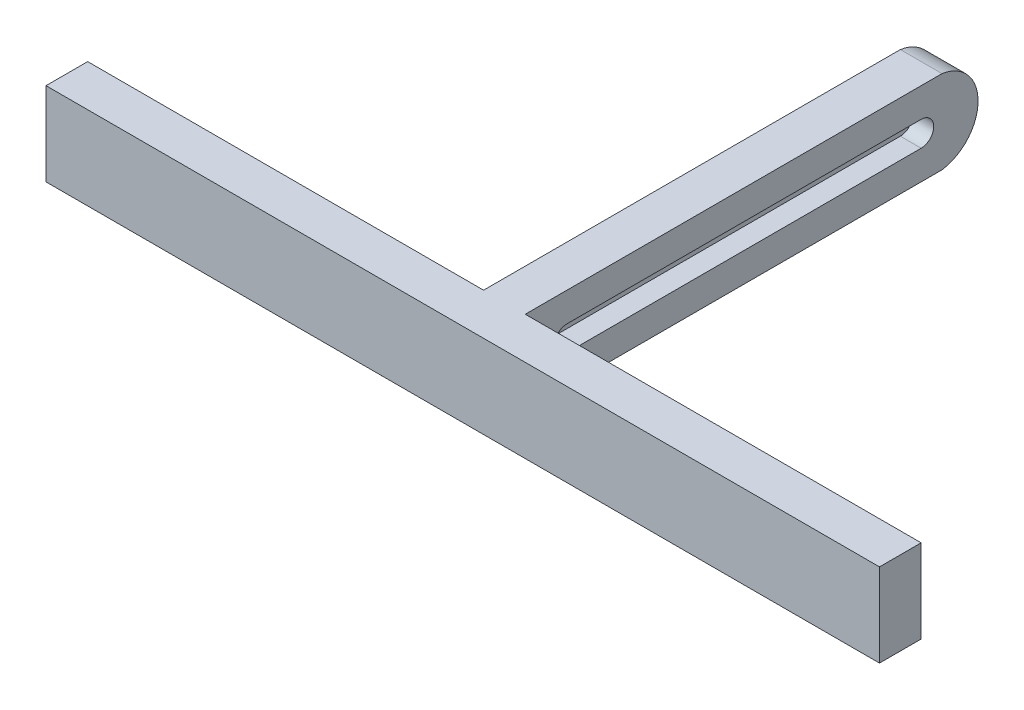
from build123d import *

# Parameters (mm, degrees)
BACK_START      = -5
SKETCH1_W       = 100
SKETCH1_H       = 20
BACK_DEPTH      = 10
CURVE_START     = -5
CURVE_END_DEPTH = 10
SLOT_START      = 5
SLOT_DEPTH      = 5
FRONT_START     = -100
SKETCH11_W      = 10
SKETCH11_H      = 20
FRONT_DEPTH     = 200


with BuildPart() as part:
    # Sketch1 → Back (new body)
    with BuildSketch(Plane(origin=(0, 0, 0), x_dir=(0, 0, -1), z_dir=(1, 0, 0)).offset(BACK_START)):
        Rectangle(SKETCH1_W, SKETCH1_H)
    extrude(amount=BACK_DEPTH)

    # Sketch5 → Curve End (add)
    with BuildSketch(Plane(origin=(0, 0, 0), x_dir=(0, 0, -1), z_dir=(1, 0, 0)).offset(CURVE_START)):
        with BuildLine():
            ThreePointArc((50, 10), (58.658985764, 0), (50, -10))
            Line((50, -10), (48.569993907, -0.102773996))
            ThreePointArc((48.569993907, -0.102773996), (48.658985764, 0), (48.569993907, 0.102773996))
            Line((48.569993907, 0.102773996), (50, 10))
        make_face()
    extrude(amount=CURVE_END_DEPTH)

    # Sketch7 → Slot (cut)
    with BuildSketch(Plane(origin=(0, 0, 0), x_dir=(0, 0, -1), z_dir=(1, 0, 0)).offset(SLOT_START)):
        with BuildLine():
            Line((-40, 3), (45, 3))
            ThreePointArc((45, 3), (48, 0), (45, -3))
            Line((45, -3), (-40, -3))
            ThreePointArc((-40, -3), (-43, 0), (-40, 3))
        make_face()
    extrude(amount=-SLOT_DEPTH, mode=Mode.SUBTRACT)

    # Sketch11 → Front (add)
    with BuildSketch(Plane(origin=(0, 0, 0), x_dir=(0, 0, -1), z_dir=(1, 0, 0)).offset(FRONT_START)):
        with Locations((-55, 0)):
            Rectangle(SKETCH11_W, SKETCH11_H)
    extrude(amount=FRONT_DEPTH)


solid = part.part
